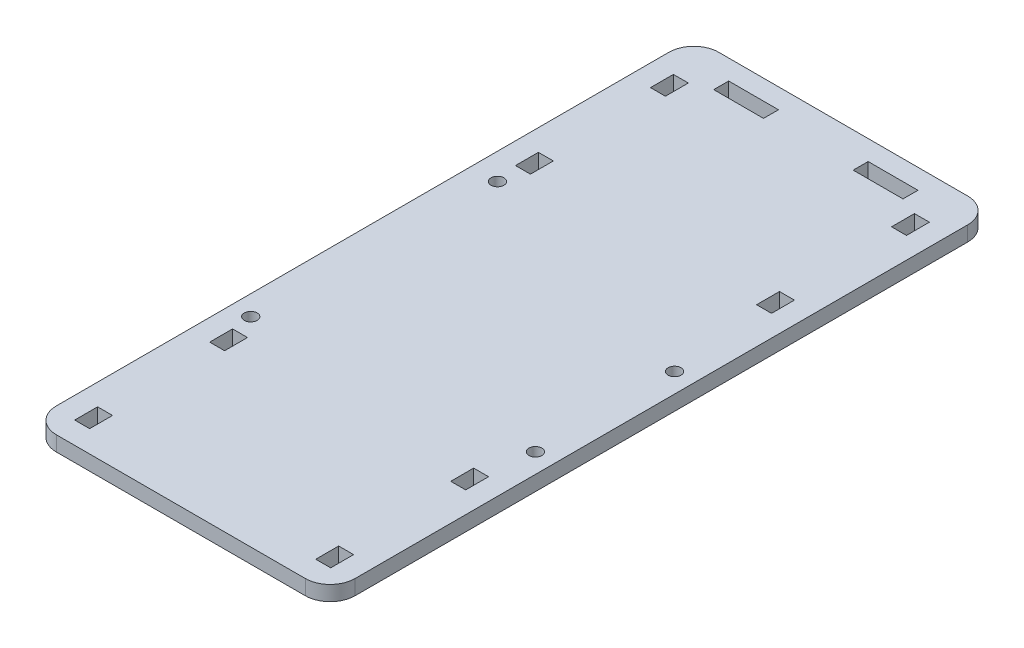
from build123d import *

# Parameters (mm, degrees)
SKETCH1_R           = 1.3
SKETCH1_W           = 10
SKETCH1_H           = 3
SKETCH1_W_2         = 3
SKETCH1_H_2         = 4.6
BOSS_EXTRUDE1_DEPTH = 3


with BuildPart() as part:
    # Sketch1 → Boss-Extrude1 (new body)
    with BuildSketch(Plane(origin=(0, 0, 0), x_dir=(1, 0, 0), z_dir=(0, 1, 0))):
        with BuildLine():
            Line((0, -20), (0, 103))
            ThreePointArc((0, 103), (1.464466094, 106.535533906), (5, 108))
            Line((5, 108), (55, 108))
            ThreePointArc((55, 108), (58.535533906, 106.535533906), (60, 103))
            Line((60, 103), (60, -20))
            ThreePointArc((60, -20), (58.535533906, -23.535533906), (55, -25))
            Line((55, -25), (5, -25))
            ThreePointArc((5, -25), (1.464466094, -23.535533906), (0, -20))
        make_face()
        with Locations((56.07, 48.068886064)):
            Circle(SKETCH1_R, mode=Mode.SUBTRACT)
        with Locations((4, 15.048886064)):
            Circle(SKETCH1_R, mode=Mode.SUBTRACT)
        with Locations((56.07, 20.128886064)):
            Circle(SKETCH1_R, mode=Mode.SUBTRACT)
        with Locations((5.27, 63.308886064)):
            Circle(SKETCH1_R, mode=Mode.SUBTRACT)
        with Locations((16, 102.5)):
            Rectangle(SKETCH1_W, SKETCH1_H, mode=Mode.SUBTRACT)
        with Locations((44, 102.5)):
            Rectangle(SKETCH1_W, SKETCH1_H, mode=Mode.SUBTRACT)
        with Locations((5.8, 97.3)):
            Rectangle(SKETCH1_W_2, SKETCH1_H_2, mode=Mode.SUBTRACT)
        with Locations((5.8, 70.2)):
            Rectangle(SKETCH1_W_2, SKETCH1_H_2, mode=Mode.SUBTRACT)
        with Locations((54.2, 70.2)):
            Rectangle(SKETCH1_W_2, SKETCH1_H_2, mode=Mode.SUBTRACT)
        with Locations((54.2, 97.3)):
            Rectangle(SKETCH1_W_2, SKETCH1_H_2, mode=Mode.SUBTRACT)
        with Locations((5.8, 8.8)):
            Rectangle(SKETCH1_W_2, SKETCH1_H_2, mode=Mode.SUBTRACT)
        with Locations((5.8, -18.3)):
            Rectangle(SKETCH1_W_2, SKETCH1_H_2, mode=Mode.SUBTRACT)
        with Locations((54.2, 8.8)):
            Rectangle(SKETCH1_W_2, SKETCH1_H_2, mode=Mode.SUBTRACT)
        with Locations((54.2, -18.3)):
            Rectangle(SKETCH1_W_2, SKETCH1_H_2, mode=Mode.SUBTRACT)
    extrude(amount=BOSS_EXTRUDE1_DEPTH)


solid = part.part
